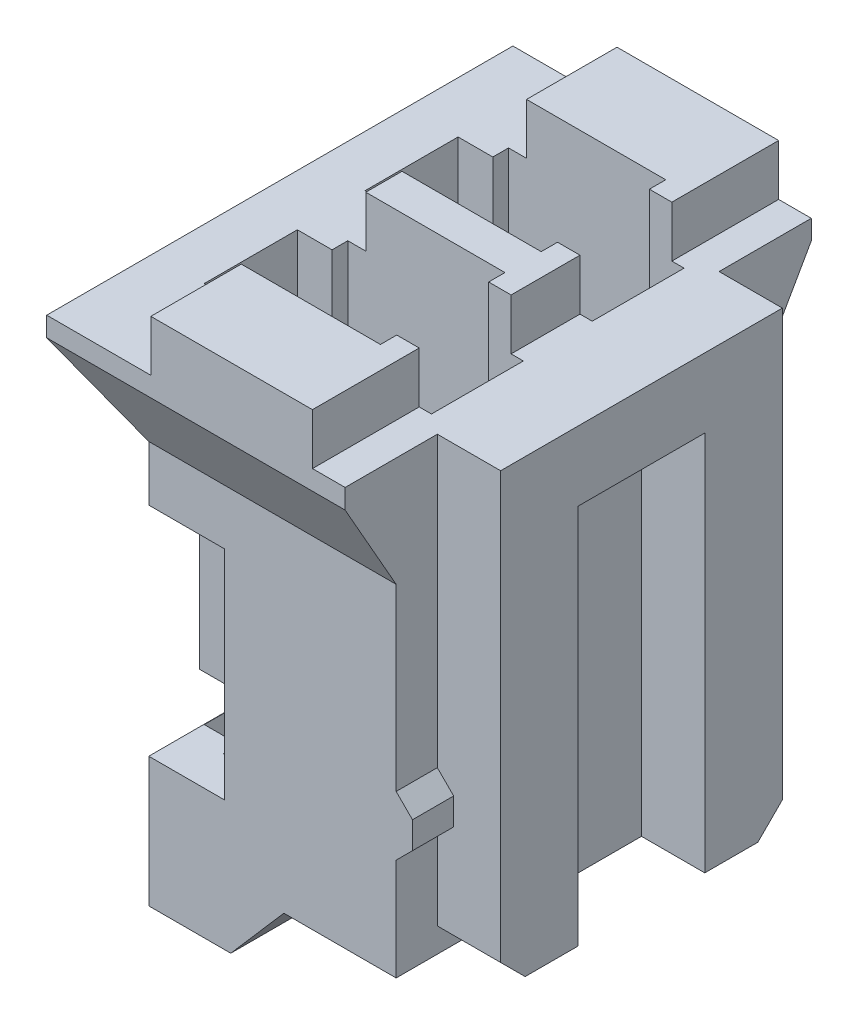
from build123d import *

# Parameters (mm, degrees)
SKETCH1_W                  = 4.5
SKETCH1_H                  = 5.8
EXTRUDE1_DEPTH             = 7
SKETCH10_W                 = 1.2954
SKETCH10_H                 = 0.635
SKETCH10_W_2               = 1.1938
CUT_EXTRUDE7_DEPTH         = 6.8
CUT_EXTRUDE13_DEPTH        = 5.5
SKETCH3_W                  = 1.0668
SKETCH3_H                  = 1.0668
MATING_SIDE_CHAMFERS_DEPTH = 0.508
MATING_SIDE_CHAMFERS_TAPER = 45
SKETCH18_W                 = 5.8
SKETCH18_H                 = 7
POLARIZING_KEYWAY_DEPTH    = 0.7874
SKETCH4_W                  = 0.8668
SKETCH4_H                  = 0.8668
TERMINAL_HOLES_DEPTH       = 8
SKETCH14_W                 = 0.8668
SKETCH14_H                 = 0.8668
TERMINAL_CUTOUT_DEPTH      = 5.73
RAMP1_DEPTH                = 0.7874
TERMINALLOCK_CUTOUT_DEPTH  = 0.9398
SKETCH20_W                 = 0.249
SKETCH20_H                 = 2.7051
CUT_EXTRUDE16_DEPTH        = 0.9398
LPATTERN2_COUNT            = 2
LPATTERN2_PITCH            = 2


with BuildPart() as part:
    # Sketch1 → Extrude1 (new body)
    with BuildSketch(Plane(origin=(0, 0, 0), x_dir=(1, 0, 0), z_dir=(0, 1, 0))):
        Rectangle(SKETCH1_W, SKETCH1_H)
    extrude(amount=EXTRUDE1_DEPTH)

    # Sketch10 → Cut-Extrude7 (cut, through all)
    with BuildSketch(Plane(origin=(0, 4.9, 2.9), x_dir=(1, 0, 0), z_dir=(0, 0, -1))):
        Polygon((-0.5948, 4.9), (0.0656, 4.138), (2.25, 4.138), (2.25, 4.9), align=None)
        Polygon((-2.25, -1.2214), (-1.615, -0.1038), (-1.615, 4.9), (-2.25, 4.9), align=None)
        with Locations((-1.6023, -1.7825)):
            Rectangle(SKETCH10_W, SKETCH10_H)
        with Locations((1.6531, -1.7825)):
            Rectangle(SKETCH10_W_2, SKETCH10_H)
    extrude(amount=CUT_EXTRUDE7_DEPTH, mode=Mode.SUBTRACT)

    # Sketch17 → Cut-Extrude13 (cut, through all)
    with BuildSketch(Plane(origin=(2.25, 0, 0), x_dir=(0, 0, -1), z_dir=(1, 0, 0))):
        Polygon((-2.9, 0), (-2.265, 0), (-2.265, 5.0038), (-2.9, 6.1214), align=None)
        Polygon((2.9, 0), (2.265, 0), (2.265, 5.0038), (2.9, 6.1214), align=None)
    extrude(amount=-CUT_EXTRUDE13_DEPTH, mode=Mode.SUBTRACT)

    # Sketch3 → Mating Side Chamfers (cut)
    with BuildSketch(Plane.XZ.offset(-0.762)):
        with Locations((0.699, 1)):
            Rectangle(SKETCH3_W, SKETCH3_H)
    mating_side_chamfers = extrude(amount=-MATING_SIDE_CHAMFERS_DEPTH, taper=MATING_SIDE_CHAMFERS_TAPER, mode=Mode.SUBTRACT)

    # Sketch18 → Polarizing Keyway (cut)
    with BuildSketch(Plane(origin=(2.25, 0, 0), x_dir=(0, 0, -1), z_dir=(1, 0, 0))):
        with Locations((0, 3.5)):
            Rectangle(SKETCH18_W, SKETCH18_H)
        Polygon((0.7874, 0.762), (0.7874, 5.5014), (-0.7874, 5.5014), (-0.7874, 0.762), (-1.4478, 0.762), (-1.7526, 1.0668), (-1.7526, 6.365), (1.7526, 6.365), (1.7526, 1.0668), (1.4478, 0.762), align=None, mode=Mode.SUBTRACT)
    extrude(amount=-POLARIZING_KEYWAY_DEPTH, mode=Mode.SUBTRACT)

    # Sketch4 → Terminal Holes (cut, through all)
    with BuildSketch(Plane.XZ):
        with Locations((0.699, 1)):
            Rectangle(SKETCH4_W, SKETCH4_H)
    terminal_holes = extrude(amount=-TERMINAL_HOLES_DEPTH, mode=Mode.SUBTRACT)

    # Sketch14 → Terminal Cutout (cut)
    with BuildSketch(Plane(origin=(0, 7, 0), x_dir=(-1, 0, 0), z_dir=(0, 1, 0))):
        Polygon((1.6108, 0.42074158), (1.6108, 1.57925842), (1.179, 1.57925842), (1.179, 1.7747), (-0.7768, 1.7747), (-0.7768, 1.5715), (-1.2086, 1.5715), (-1.2086, 1), (-1.2086, 0.4285), (-0.7768, 0.4285), (-0.7768, 0.2253), (1.179, 0.2253), (1.179, 0.42074158), align=None)
        with Locations((-0.699, 1)):
            Rectangle(SKETCH14_W, SKETCH14_H, mode=Mode.SUBTRACT)
    terminal_cutout = extrude(amount=-TERMINAL_CUTOUT_DEPTH, mode=Mode.SUBTRACT)

    # Sketch11 → Ramp1 (add)
    with BuildSketch(Plane.XY.offset(2.265)):
        Polygon((1.4626, 2.77196042), (1.4626, 2.032), (1.6658, 2.2352), (1.6658, 2.56876042), align=None)
    ramp1 = extrude(amount=-RAMP1_DEPTH)

    # Sketch19 → TerminalLock Cutout (cut)
    with BuildSketch(Plane.ZY.offset(1.615)):
        Polygon((0.365, 4.318), (0.365, 2.2352), (1.635, 2.2352), (1.635, 4.318), (2.016, 4.318), (2.016, 1.6129), (1.2921, 1.6129), (1.2921, 0.5842), (0.7079, 0.5842), (0.7079, 1.6129), (-0.016, 1.6129), (-0.016, 4.318), align=None)
    terminallock_cutout = extrude(amount=-TERMINALLOCK_CUTOUT_DEPTH, mode=Mode.SUBTRACT)

    # Sketch20 → Cut-Extrude16 (cut)
    with BuildSketch(Plane.ZY.offset(1.615)):
        with Locations((2.1405, 2.96545)):
            Rectangle(SKETCH20_W, SKETCH20_H)
        with Locations((-2.1405, 2.96545)):
            Rectangle(SKETCH20_W, SKETCH20_H)
    extrude(amount=-CUT_EXTRUDE16_DEPTH, mode=Mode.SUBTRACT)

    # LPattern2: Mating Side Chamfers, Terminal Holes, Terminal Cutout, TerminalLock Cutout ×2
    with Locations(*[(0, 0, -i * LPATTERN2_PITCH) for i in range(1, LPATTERN2_COUNT)]):
        add(mating_side_chamfers, mode=Mode.SUBTRACT)
        add(terminal_holes, mode=Mode.SUBTRACT)
        add(terminal_cutout, mode=Mode.SUBTRACT)
        add(terminallock_cutout, mode=Mode.SUBTRACT)

    # Mirror1: Ramp1 across plane
    add(ramp1.mirror(Plane.XY))


solid = part.part
